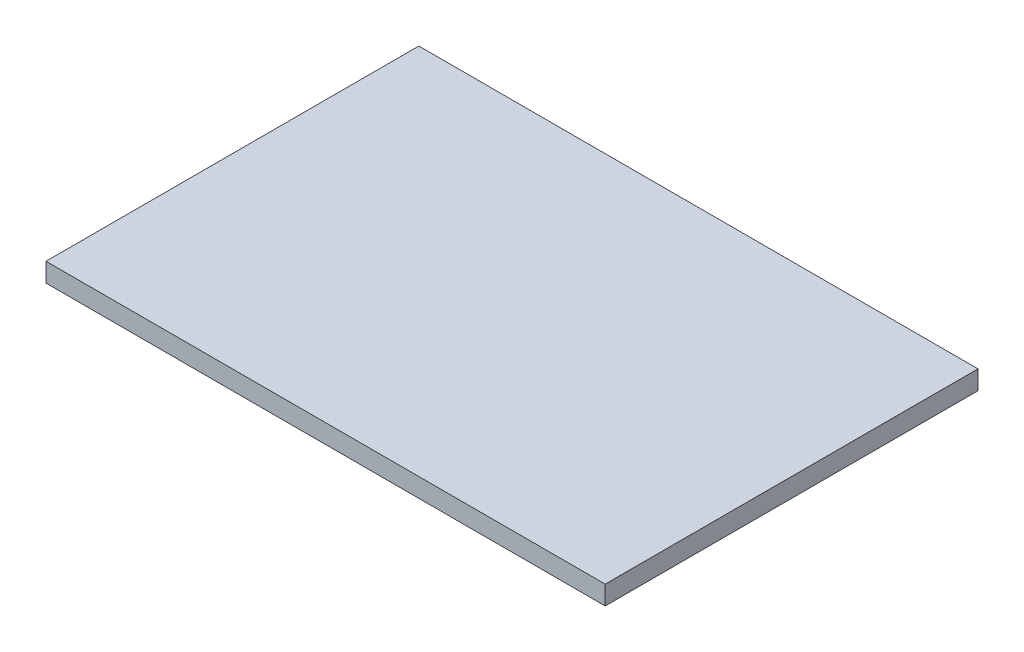
from build123d import *

# Parameters (mm, degrees)
CROQUIS1_W              = 750
CROQUIS1_H              = 500
SALIENTE_EXTRUIR1_DEPTH = 25.4


with BuildPart() as part:
    # Croquis1 → Saliente-Extruir1 (new body)
    with BuildSketch(Plane(origin=(0, 0, 0), x_dir=(1, 0, 0), z_dir=(0, 1, 0))):
        Rectangle(CROQUIS1_W, CROQUIS1_H)
    extrude(amount=SALIENTE_EXTRUIR1_DEPTH)


solid = part.part
